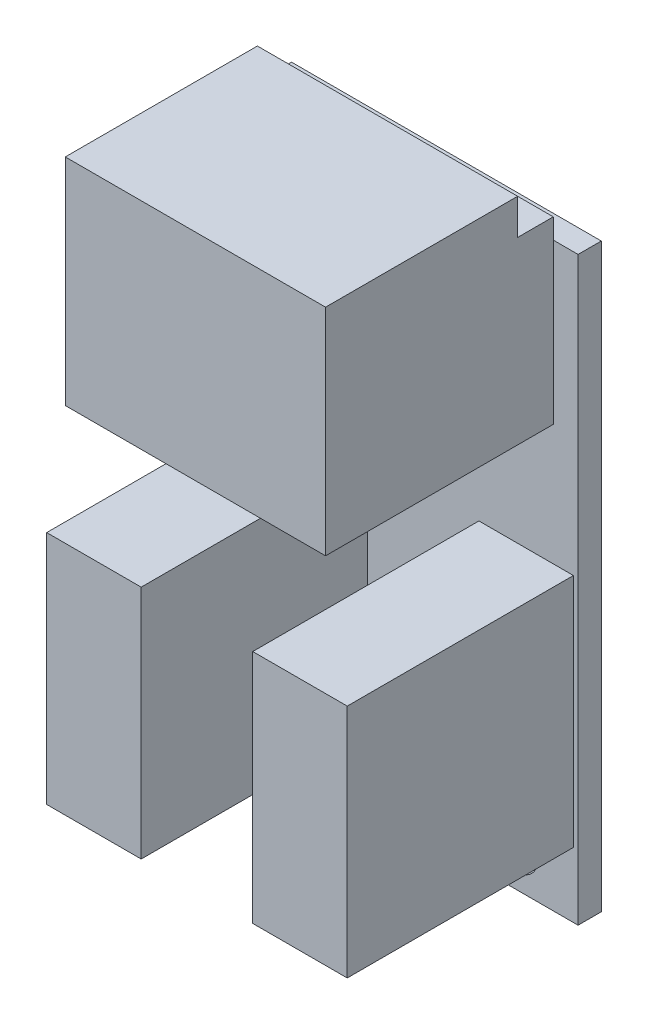
from build123d import *

# Parameters (mm, degrees)
CROQUIS1_W              = 20
CROQUIS1_H              = 37.5
CROQUIS1_R              = 1.35
SALIENTE_EXTRUIR1_DEPTH = 1.5
CROQUIS2_W              = 16.8
CROQUIS2_H              = 11.6
SALIENTE_EXTRUIR2_DEPTH = 2.3
CROQUIS3_W              = 16.8
CROQUIS3_H              = 13.9
SALIENTE_EXTRUIR3_DEPTH = 12.4
CROQUIS4_W              = 6.1
CROQUIS4_H              = 15.2
SALIENTE_EXTRUIR4_DEPTH = 14.6


with BuildPart() as part:
    # Croquis1 → Saliente-Extruir1 (new body)
    with BuildSketch(Plane.XY):
        Rectangle(CROQUIS1_W, CROQUIS1_H)
        with Locations((-6.05, -16.4)):
            Circle(CROQUIS1_R, mode=Mode.SUBTRACT)
        with Locations((6.05, -16.4)):
            Circle(CROQUIS1_R, mode=Mode.SUBTRACT)
    extrude(amount=SALIENTE_EXTRUIR1_DEPTH)

    # Croquis2 → Saliente-Extruir2 (add)
    with BuildSketch(Plane.XY.offset(1.5)):
        with Locations((0, 14.25)):
            Rectangle(CROQUIS2_W, CROQUIS2_H)
    extrude(amount=SALIENTE_EXTRUIR2_DEPTH)

    # Croquis3 → Saliente-Extruir3 (add)
    with BuildSketch(Plane.XY.offset(3.8)):
        with Locations((0, 15.4)):
            Rectangle(CROQUIS3_W, CROQUIS3_H)
    extrude(amount=SALIENTE_EXTRUIR3_DEPTH)

    # Croquis4 → Saliente-Extruir4 (add)
    with BuildSketch(Plane.XY.offset(1.5)):
        with Locations((-6.65, -6.95)):
            Rectangle(CROQUIS4_W, CROQUIS4_H)
        with Locations((6.65, -6.95)):
            Rectangle(CROQUIS4_W, CROQUIS4_H)
    extrude(amount=SALIENTE_EXTRUIR4_DEPTH)


solid = part.part
